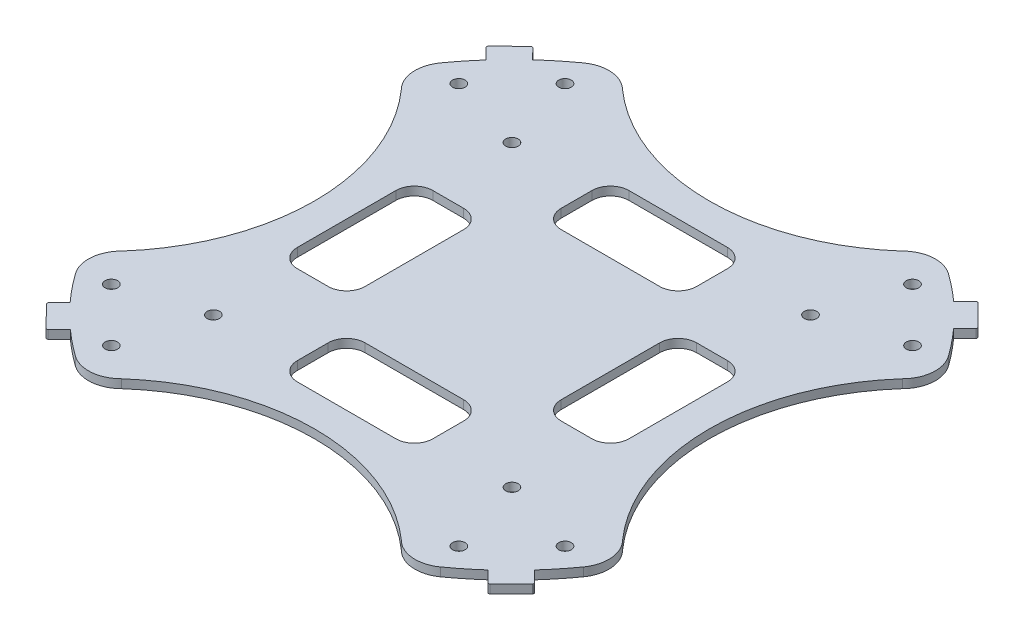
from build123d import *

# Parameters (mm, degrees)
SKETCH1_R           = 1.015999997
SKETCH1_R_2         = 1.015999998
BOSS_EXTRUDE1_DEPTH = 1.397
CUT_EXTRUDE1_DEPTH  = 1.397


with BuildPart() as part:
    # Sketch1 → Boss-Extrude1 (new body)
    with BuildSketch(Plane(origin=(0, 0, 0), x_dir=(1, 0, 0), z_dir=(0, 1, 0))):
        with BuildLine():
            Line((39.582900137, 36.114993353), (36.135807663, 39.558338119))
            ThreePointArc((36.135807663, 39.558338119), (35.957741585, 39.627761729), (35.781684056, 39.553391627))
            Line((35.781684056, 39.553391627), (33.985632879, 37.75734045))
            ThreePointArc((33.985632879, 37.75734045), (31.864995739, 39.563392759), (29.648553616, 41.25049416))
            ThreePointArc((29.648553616, 41.25049416), (26.08463695, 42.240855836), (22.7274362, 40.687948442))
            ThreePointArc((22.7274362, 40.687948442), (0, 32.054645119), (-22.7274362, 40.687948442))
            ThreePointArc((-22.7274362, 40.687948442), (-26.08463695, 42.240855836), (-29.648553616, 41.25049416))
            ThreePointArc((-29.648553616, 41.25049416), (-31.979190339, 39.471146237), (-34.203281642, 37.560291864))
            Line((-34.203281642, 37.560291864), (-35.891842785, 39.288069847))
            ThreePointArc((-35.891842785, 39.288069847), (-36.070582137, 39.364521411), (-36.251029365, 39.292193022))
            Line((-36.251029365, 39.292193022), (-39.722106603, 35.899901777))
            ThreePointArc((-39.722106603, 35.899901777), (-39.798570717, 35.719704686), (-39.724180022, 35.538641777))
            Line((-39.724180022, 35.538641777), (-37.952779126, 33.76724088))
            ThreePointArc((-37.952779126, 33.76724088), (-39.65514495, 31.750739818), (-41.25049416, 29.648553616))
            ThreePointArc((-41.25049416, 29.648553616), (-42.240855836, 26.08463695), (-40.687948442, 22.7274362))
            ThreePointArc((-40.687948442, 22.7274362), (-32.054645119, 0), (-40.687948442, -22.7274362))
            ThreePointArc((-40.687948442, -22.7274362), (-42.240855836, -26.08463695), (-41.25049416, -29.648553616))
            ThreePointArc((-41.25049416, -29.648553616), (-39.491481287, -31.954074947), (-37.603777167, -34.155467245))
            Line((-37.603777167, -34.155467245), (-39.342333505, -35.894023583))
            ThreePointArc((-39.342333505, -35.894023583), (-39.416724199, -36.072170919), (-39.34438326, -36.251160408))
            Line((-39.34438326, -36.251160408), (-35.996846779, -39.67644344))
            ThreePointArc((-35.996846779, -39.67644344), (-35.8116648, -39.777312417), (-35.614113895, -39.703552292))
            Line((-35.614113895, -39.703552292), (-33.818062671, -37.907501068))
            ThreePointArc((-33.818062671, -37.907501068), (-31.777299231, -39.633864984), (-29.648553616, -41.25049416))
            ThreePointArc((-29.648553616, -41.25049416), (-26.08463695, -42.240855836), (-22.7274362, -40.687948442))
            ThreePointArc((-22.7274362, -40.687948442), (0, -32.054645119), (22.7274362, -40.687948442))
            ThreePointArc((22.7274362, -40.687948442), (26.08463695, -42.240855836), (29.648553616, -41.25049416))
            ThreePointArc((29.648553616, -41.25049416), (31.839816037, -39.583659694), (33.937557164, -37.800558378))
            Line((33.937557164, -37.800558378), (35.712874192, -39.617107153))
            ThreePointArc((35.712874192, -39.617107153), (35.89865706, -39.693541904), (36.081857691, -39.611109667))
            Line((36.081857691, -39.611109667), (39.53818925, -36.154778109))
            ThreePointArc((39.53818925, -36.154778109), (39.581113192, -35.9880354), (39.507835585, -35.832227866))
            Line((39.507835585, -35.832227866), (37.71178436, -34.036176641))
            ThreePointArc((37.71178436, -34.036176641), (39.542043021, -31.891485286), (41.25049416, -29.648553616))
            ThreePointArc((41.25049416, -29.648553616), (42.240855836, -26.08463695), (40.687948442, -22.7274362))
            ThreePointArc((40.687948442, -22.7274362), (32.054645119, 0), (40.687948442, 22.7274362))
            ThreePointArc((40.687948442, 22.7274362), (42.240855836, 26.08463695), (41.25049416, 29.648553616))
            ThreePointArc((41.25049416, 29.648553616), (39.563392759, 31.864995739), (37.75734045, 33.985632879))
            Line((37.75734045, 33.985632879), (39.573889176, 35.76094986))
            ThreePointArc((39.573889176, 35.76094986), (39.650275245, 35.936142133), (39.582900137, 36.114993353))
        make_face()
        with Locations((-28.220170249, 36.841216125)):
            Circle(SKETCH1_R, mode=Mode.SUBTRACT)
        with Locations((-36.841216125, 28.220170249)):
            Circle(SKETCH1_R, mode=Mode.SUBTRACT)
        with Locations((-24.24546392, 24.24546392)):
            Circle(SKETCH1_R_2, mode=Mode.SUBTRACT)
        with Locations((28.220170249, 36.841216125)):
            Circle(SKETCH1_R, mode=Mode.SUBTRACT)
        with Locations((36.841216125, 28.220170249)):
            Circle(SKETCH1_R, mode=Mode.SUBTRACT)
        with Locations((24.24546392, 24.24546392)):
            Circle(SKETCH1_R_2, mode=Mode.SUBTRACT)
        with Locations((36.841216125, -28.220170249)):
            Circle(SKETCH1_R, mode=Mode.SUBTRACT)
        with Locations((28.220170249, -36.841216125)):
            Circle(SKETCH1_R, mode=Mode.SUBTRACT)
        with Locations((24.24546392, -24.24546392)):
            Circle(SKETCH1_R_2, mode=Mode.SUBTRACT)
        with Locations((-28.220170249, -36.841216125)):
            Circle(SKETCH1_R, mode=Mode.SUBTRACT)
        with Locations((-36.841216125, -28.220170249)):
            Circle(SKETCH1_R, mode=Mode.SUBTRACT)
        with Locations((-24.24546392, -24.24546392)):
            Circle(SKETCH1_R_2, mode=Mode.SUBTRACT)
    extrude(amount=BOSS_EXTRUDE1_DEPTH)

    # Sketch3 → Cut-Extrude1 (cut)
    with BuildSketch(Plane(origin=(0, 1.397, 0), x_dir=(1, 0, 0), z_dir=(0, 1, 0))):
        with BuildLine():
            Line((26.924, 8.076), (26.924, -7.924))
            ThreePointArc((26.924, -7.924), (26.045320344, -10.045320344), (23.924, -10.924))
            Line((23.924, -10.924), (18.924, -10.924))
            ThreePointArc((18.924, -10.924), (16.802679656, -10.045320344), (15.924, -7.924))
            Line((15.924, -7.924), (15.924, 8.076))
            ThreePointArc((15.924, 8.076), (16.802679656, 10.197320344), (18.924, 11.076))
            Line((18.924, 11.076), (23.924, 11.076))
            ThreePointArc((23.924, 11.076), (26.045320344, 10.197320344), (26.924, 8.076))
        make_face()
        with BuildLine():
            Line((-8, 27), (8, 27))
            ThreePointArc((8, 27), (10.121320344, 26.121320344), (11, 24))
            Line((11, 24), (11, 19))
            ThreePointArc((11, 19), (10.121320344, 16.878679656), (8, 16))
            Line((8, 16), (-8, 16))
            ThreePointArc((-8, 16), (-10.121320344, 16.878679656), (-11, 19))
            Line((-11, 19), (-11, 24))
            ThreePointArc((-11, 24), (-10.121320344, 26.121320344), (-8, 27))
        make_face()
        with BuildLine():
            Line((8, -26.848), (-8, -26.848))
            ThreePointArc((-8, -26.848), (-10.121320344, -25.969320344), (-11, -23.848))
            Line((-11, -23.848), (-11, -18.848))
            ThreePointArc((-11, -18.848), (-10.121320344, -16.726679656), (-8, -15.848))
            Line((-8, -15.848), (8, -15.848))
            ThreePointArc((8, -15.848), (10.121320344, -16.726679656), (11, -18.848))
            Line((11, -18.848), (11, -23.848))
            ThreePointArc((11, -23.848), (10.121320344, -25.969320344), (8, -26.848))
        make_face()
        with BuildLine():
            Line((-26.924, -7.924), (-26.924, 8.076))
            ThreePointArc((-26.924, 8.076), (-26.045320344, 10.197320344), (-23.924, 11.076))
            Line((-23.924, 11.076), (-18.924, 11.076))
            ThreePointArc((-18.924, 11.076), (-16.802679656, 10.197320344), (-15.924, 8.076))
            Line((-15.924, 8.076), (-15.924, -7.924))
            ThreePointArc((-15.924, -7.924), (-16.802679656, -10.045320344), (-18.924, -10.924))
            Line((-18.924, -10.924), (-23.924, -10.924))
            ThreePointArc((-23.924, -10.924), (-26.045320344, -10.045320344), (-26.924, -7.924))
        make_face()
    extrude(amount=-CUT_EXTRUDE1_DEPTH, mode=Mode.SUBTRACT)


solid = part.part
